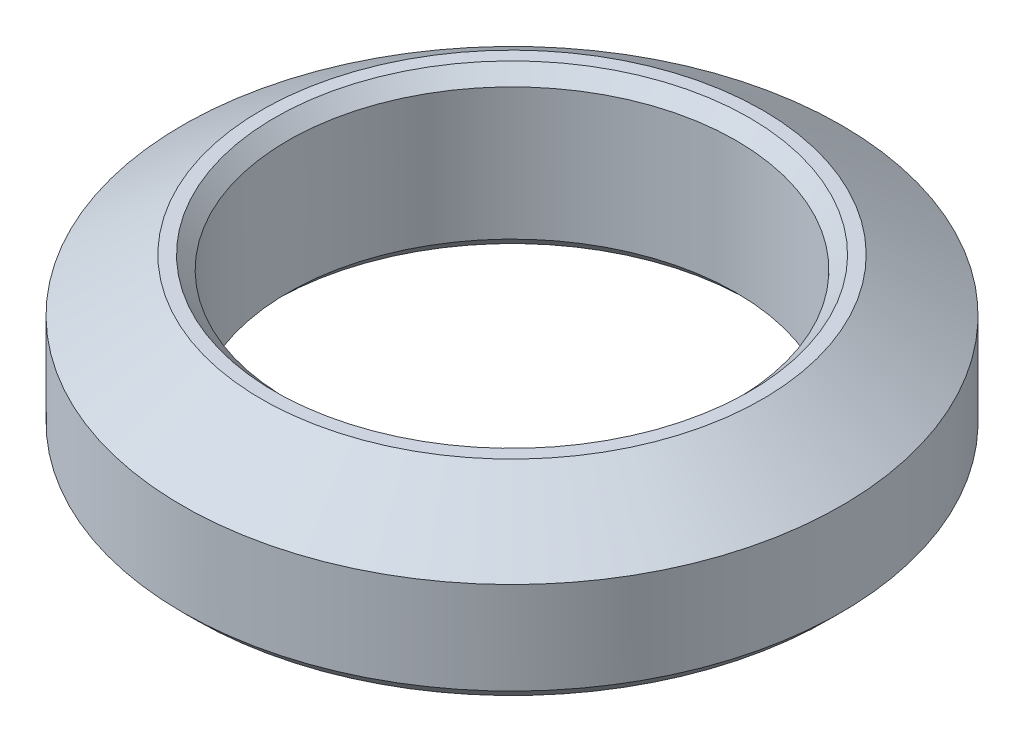
from build123d import *

# Parameters (mm, degrees)
CHAMFER1_SIZE = 0.25


with BuildPart() as part:
    # Sketch1 → Revolve1 (revolve)
    with BuildSketch(Plane.XY):
        Polygon((-4.25, 3), (-4.25, 0), (-6.25, 0), (-6.25, 2), (-4.75, 3), align=None)
    revolve(axis=Axis((0, 0, 0), (0, 1, 0)))

    # Chamfer1
    chamfer1_edges = [part.edges().sort_by_distance(p)[0] for p in [
        (6.25, 0, 0),
        (4.25, 0, 0),
        (4.25, 3, 0),
    ]]
    chamfer(chamfer1_edges, length=CHAMFER1_SIZE)


solid = part.part
